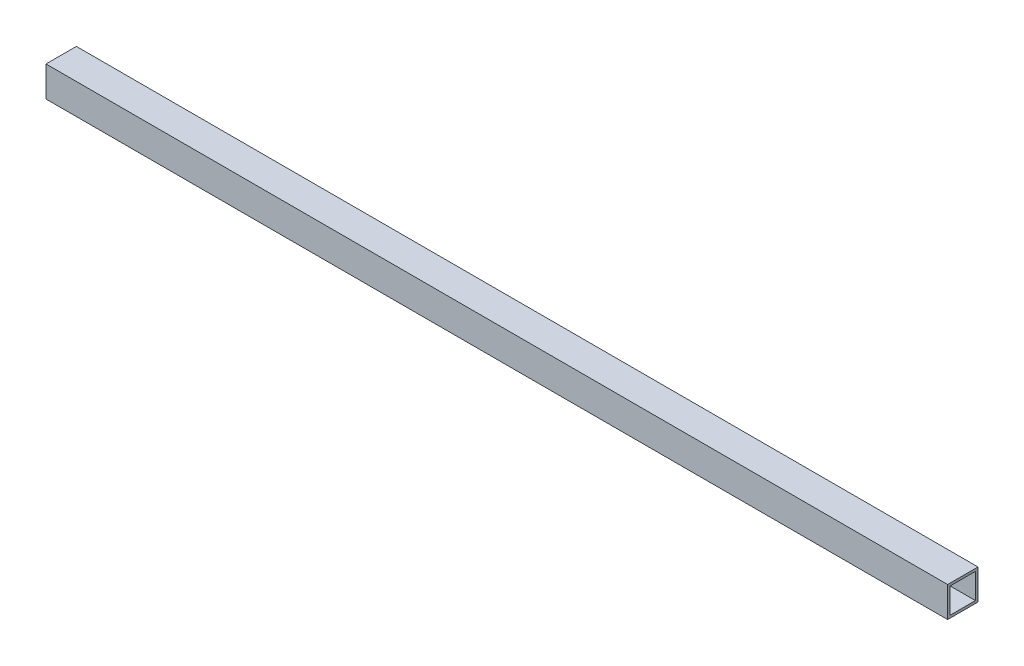
from build123d import *

# Parameters (mm, degrees)
CROQUIS1_W              = 19.05
CROQUIS1_H              = 19.05
CROQUIS1_W_2            = 15.875
CROQUIS1_H_2            = 15.875
SALIENTE_EXTRUIR1_DEPTH = 282.575


with BuildPart() as part:
    # Croquis1 → Saliente-Extruir1 (new body, symmetric)
    with BuildSketch(Plane(origin=(0, 0, 0), x_dir=(0, 0, -1), z_dir=(1, 0, 0))):
        Rectangle(CROQUIS1_W, CROQUIS1_H)
        Rectangle(CROQUIS1_W_2, CROQUIS1_H_2, mode=Mode.SUBTRACT)
    extrude(amount=SALIENTE_EXTRUIR1_DEPTH, both=True)


solid = part.part
